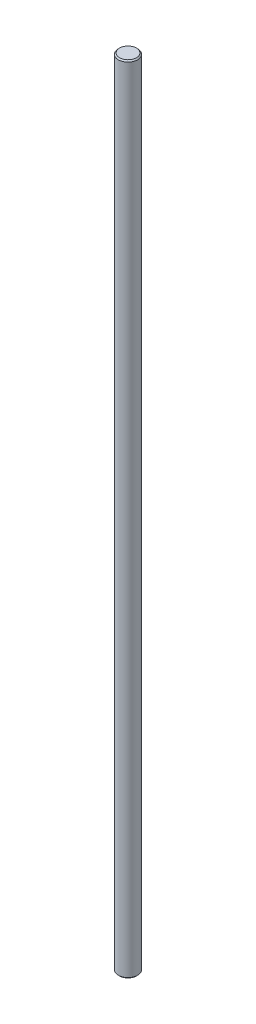
from build123d import *

# Parameters (mm, degrees)
SKETCH1_R           = 4
BOSS_EXTRUDE1_DEPTH = 330.2
CHAMFER1_SIZE       = 0.5


with BuildPart() as part:
    # Sketch1 → Boss-Extrude1 (new body)
    with BuildSketch(Plane(origin=(0, 0, 0), x_dir=(1, 0, 0), z_dir=(0, 1, 0))):
        Circle(SKETCH1_R)
    extrude(amount=BOSS_EXTRUDE1_DEPTH)

    # Chamfer1
    chamfer1_edges = [part.edges().sort_by_distance(p)[0] for p in [
        (-4, 0, 0),
        (-4, 330.2, 0),
    ]]
    chamfer(chamfer1_edges, length=CHAMFER1_SIZE)


solid = part.part
